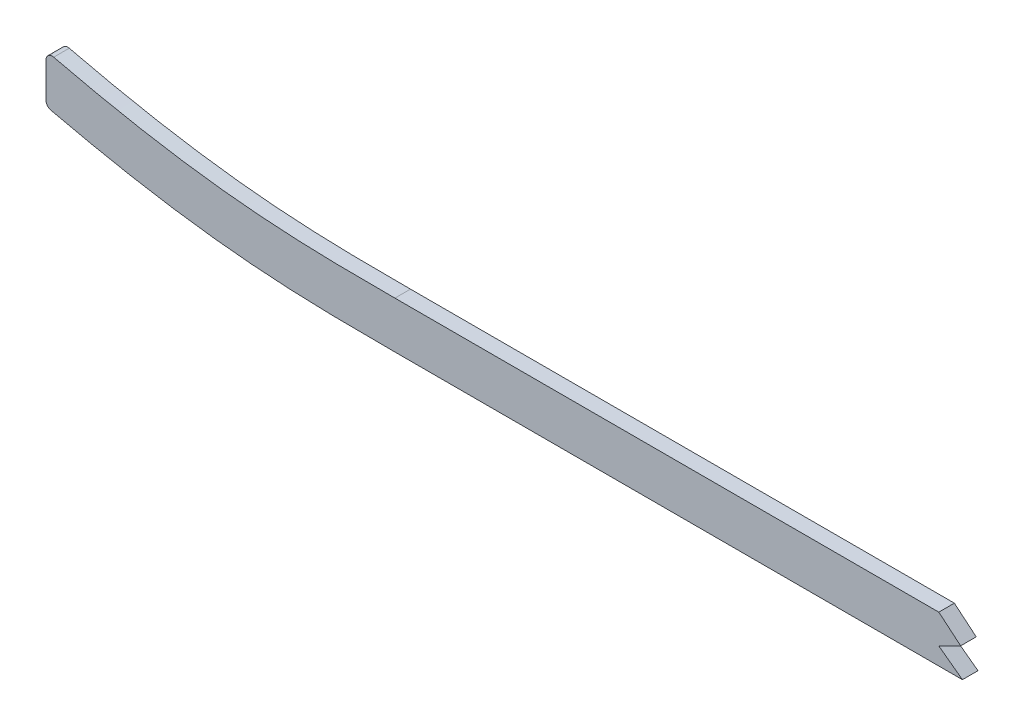
from build123d import *

# Parameters (mm, degrees)
BOSS_EXTRUDE1_DEPTH = 3.175
CUT_EXTRUDE1_DEPTH  = 7.3500001
FILLET1_R           = 2.54
CUT_EXTRUDE2_DEPTH  = 7.62


with BuildPart() as part:
    # Sketch1 → Boss-Extrude1 (new body, symmetric)
    with BuildSketch(Plane.XY):
        with BuildLine():
            Line((499.61002795, -53.470702797), (1046.28548189, -53.470702797))
            add(Edge.make_bspline(
                [(2669.54, -9.569049356), (2615.393603553, -13.17073937), (2561.080658619, -16.536108081), (2506.205230446, -19.758621957), (2430.209106802, -23.505211705), (2354.212983157, -26.631486423), (2332.570330468, -27.480988169), (2156.268639429, -34.377768543), (1979.966947376, -41.628631248), (1824.114277635, -52.771265877), (1636.928606778, -53.579569849), (1449.742935921, -53.454024613), (1418.006730935, -53.470702797), (1324.899336146, -53.470702797), (1231.791940344, -53.470702797), (1170.441269319, -53.470702797), (1108.784075813, -53.470702797), (1047.126882346, -53.470702797), (1046.846414188, -53.470702797), (1046.565947184, -53.470702797), (1046.28548189, -53.470702797)],
                knots=[103.698913506, 103.698913506, 103.698913506, 103.698913506, 103.698913506, 103.698913506, 130.927896619, 130.927896619, 130.927896619, 141.337054719, 141.337054719, 141.337054719, 218.101815019, 218.101815019, 218.101815019, 233.772059419, 233.772059419, 233.772059419, 264.077723219, 264.077723219, 264.077723219, 264.2162088, 264.2162088, 264.2162088, 264.2162088, 264.2162088, 264.2162088], degree=5))
            Line((2669.54, -9.569049356), (2669.54, 9.5231025))
            add(Edge.make_bspline(
                [(2669.54, 9.5231025), (2667.126494524, 9.36235515), (2659.861586685, 8.880281494), (2635.666282302, 7.292469146), (2596.857665529, 4.826056853), (2545.729743039, 1.758344093), (2494.405305707, -1.098555235), (2451.533022267, -3.266573297), (2417.198316756, -4.86708361), (2391.457076919, -6.003589235), (2365.634736307, -7.086854581), (2339.546284672, -8.137729944), (2313.466132974, -9.165138371), (2287.612375486, -10.179478215), (2261.763347437, -11.201032297), (2227.285329715, -12.583842557), (2184.175569393, -14.36607236), (2132.429066114, -16.607427868), (2063.4255234, -19.708920485), (1977.174907635, -23.700543313), (1873.732451432, -28.149389221), (1770.37461881, -31.657468649), (1667.085687813, -33.793117556), (1581.011094491, -34.383188831), (1512.07397126, -34.4278026), (1443.061513477, -34.409510402), (1356.800927879, -34.424432812), (1218.794626954, -34.418464788), (1115.289022786, -34.420702797), (1046.28548189, -34.420702797)],
                knots=[103.571582669, 103.571582669, 103.571582669, 103.571582669, 104.300777207, 105.766098403, 110.877392287, 115.98868617, 121.099980054, 126.211273938, 128.76692088, 131.322567822, 133.878214764, 136.433861706, 138.989508647, 141.545155589, 144.100802531, 146.656449473, 151.767743357, 156.879037241, 161.990331124, 172.212918892, 182.43550666, 192.658094427, 202.880682195, 213.103269962, 218.214563846, 223.32585773, 233.548445497, 243.771033265, 264.2162088, 264.2162088, 264.2162088, 264.2162088], degree=3))
            Line((1046.28548189, -34.420702797), (499.61002795, -34.420702797))
            add(Edge.make_bspline(
                [(499.61002795, -34.420702797), (488.614737518, -34.420702797), (472.236395365, -34.420702798), (449.940231846, -34.420702794), (427.771305695, -34.42070281), (405.874681663, -34.420702712), (384.584909128, -34.420702942), (368.900229326, -34.420702244), (353.376568613, -34.420704862), (332.608466435, -34.420689186), (306.287754853, -34.420570006), (274.023487704, -34.420538256), (252.271015965, -34.420709741), (241.425150134, -34.420702761)],
                knots=[19.90682951, 19.90682951, 19.90682951, 19.90682951, 23.220120017, 24.876765271, 26.533410525, 29.846701033, 31.503346286, 33.15999154, 34.816636794, 36.473282048, 39.786572556, 43.099863063, 46.413153571, 46.413153571, 46.413153571, 46.413153571], degree=3))
            add(Edge.make_bspline(
                [(241.425150134, -34.420702761), (239.394928853, -34.420701455), (235.322322927, -34.420495867), (227.274423443, -34.398702533), (217.319360062, -34.297466855), (205.530690077, -33.976385563), (189.963341914, -33.212641271), (170.696984653, -31.543495194), (147.533261232, -28.314398128), (125.482753206, -24.202109872), (109.358914834, -20.622537553), (100.964116069, -18.612521054), (99.06, -18.149327722)],
                knots=[0, 0, 0, 0, 0.622088422, 1.244176844, 2.488353689, 3.732530533, 4.976707377, 7.465061066, 9.953414755, 12.441768444, 14.55823542, 15.180323842, 15.180323842, 15.180323842, 15.180323842], degree=3))
            Line((99.06, -18.149327722), (99.06, -37.741485304))
            add(Edge.make_bspline(
                [(241.425137875, -53.470702761), (224.286916993, -53.470691732), (207.149474967, -53.467315374), (190.203897513, -52.686577078), (161.734965878, -49.987457476), (133.266034188, -45.175583375), (121.749620566, -42.910592695), (110.349390726, -40.420274627), (99.06, -37.741485304)],
                knots=[0, 0, 0, 0, 0, 0, 8.71381608, 8.71381608, 8.71381608, 14.701907176, 14.701907176, 14.701907176, 14.701907176, 14.701907176, 14.701907176], degree=5))
            add(Edge.make_bspline(
                [(499.61002795, -53.470702797), (492.136820835, -53.470702797), (484.754348064, -53.470702797), (477.443025859, -53.470702797), (448.516583145, -53.470702797), (419.590140517, -53.470702797), (398.368118521, -53.470702797), (355.647540186, -53.470702797), (312.926961851, -53.470702797), (289.235090436, -53.470293029), (265.364963651, -53.470705034), (241.4948369, -53.470702789), (241.471603891, -53.470702785), (241.448370882, -53.470702776), (241.425137875, -53.470702761)],
                knots=[19.90682951, 19.90682951, 19.90682951, 19.90682951, 19.90682951, 19.90682951, 23.637897311, 23.637897311, 23.637897311, 34.276545571, 34.276545571, 34.276545571, 46.401340901, 46.401340901, 46.401340901, 46.413153571, 46.413153571, 46.413153571, 46.413153571, 46.413153571, 46.413153571], degree=5))
        make_face()
    extrude(amount=BOSS_EXTRUDE1_DEPTH, both=True)

    # Sketch2 → Cut-Extrude1 (cut, through all)
    with BuildSketch(Plane.XY.offset(3.175)):
        with BuildLine():
            add(Edge.make_bspline(
                [(2312.9875, -9.183260037), (2304.505441691, -9.516700376), (2287.441020622, -10.186250162), (2261.763347437, -11.201032297), (2228.230552004, -12.545932515), (2203.310445107, -13.575047161), (2187.00995947, -14.263260037)],
                knots=[139.04033329, 139.04033329, 139.04033329, 139.04033329, 141.545155589, 144.100802531, 146.656449473, 151.487488909, 151.487488909, 151.487488909, 151.487488909], degree=3))
            Line((2187.00995947, -14.263260037), (2312.9875, -14.263260037))
            Line((2312.9875, -14.263260037), (2312.9875, -9.183260037))
        make_face()
    extrude(amount=-CUT_EXTRUDE1_DEPTH, mode=Mode.SUBTRACT)

    # Fillet1
    fillet1_edges = [part.edges().sort_by_distance(p)[0] for p in [
        (2669.54, -9.569049356, -1.5875),
        (2669.54, 9.5231025, -1.5875),
        (99.06, -37.741485304, -1.5875),
        (99.06, -18.149327722, -1.5875),
        (2312.9875, -9.183260037, 1.5875),
        (2312.9875, -14.263260037, 0),
    ]]
    fillet(fillet1_edges, radius=FILLET1_R)

    # Sketch3 → Cut-Extrude2 (cut)
    with BuildSketch(Plane.XY.offset(3.175)):
        Polygon((463.358597157, -34.420702797), (472.271656585, -41.874419167), (463.358597157, -46.384200616), (472.997412797, -53.470702797), (510.09583662, -269.844988776), (2795.524214409, -269.844988776), (2811.168313051, 250.910269335), (463.358597157, 321.441226467), align=None)
    extrude(amount=-CUT_EXTRUDE2_DEPTH, mode=Mode.SUBTRACT)


solid = part.part
